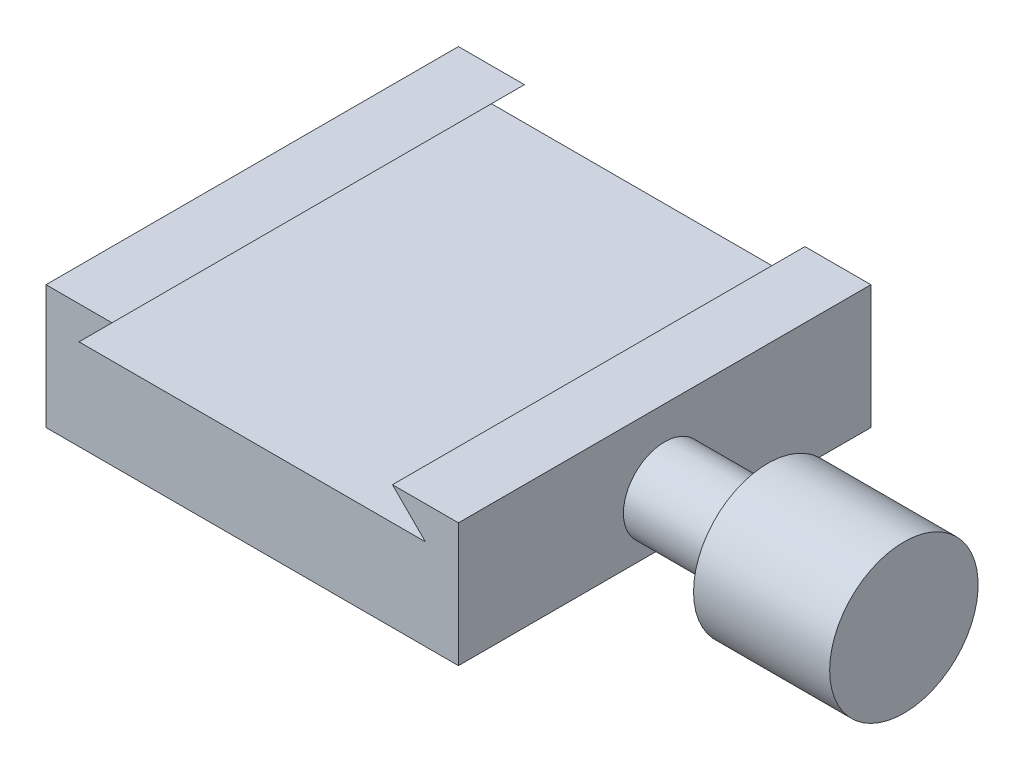
from build123d import *

# Parameters (mm, degrees)
BOSS_EXTRUDE1_DEPTH = 50
SKETCH3_R           = 4.7625
CUT_EXTRUDE1_DEPTH  = 6.35


with BuildPart() as part:
    # Sketch1 → Boss-Extrude1 (new body)
    with BuildSketch(Plane.XY):
        Polygon((0, 0), (0, 15), (8, 15), (4, 11), (46, 11), (42, 15), (50, 15), (50, 0), align=None)
    extrude(amount=BOSS_EXTRUDE1_DEPTH)

    # Sketch2 → Revolve2 (revolve)
    with BuildSketch(Plane.XY.offset(25)):
        Polygon((50, 6), (50, 1), (62.5, 1), (62.5, -3), (79, -3), (79, 6), align=None)
    revolve(axis=Axis((50, 6, 25), (1, 0, 0)))

    # Sketch3 → Cut-Extrude1 (cut)
    with BuildSketch(Plane.XZ):
        with Locations((25, 25)):
            Circle(SKETCH3_R)
    extrude(amount=-CUT_EXTRUDE1_DEPTH, mode=Mode.SUBTRACT)


solid = part.part
